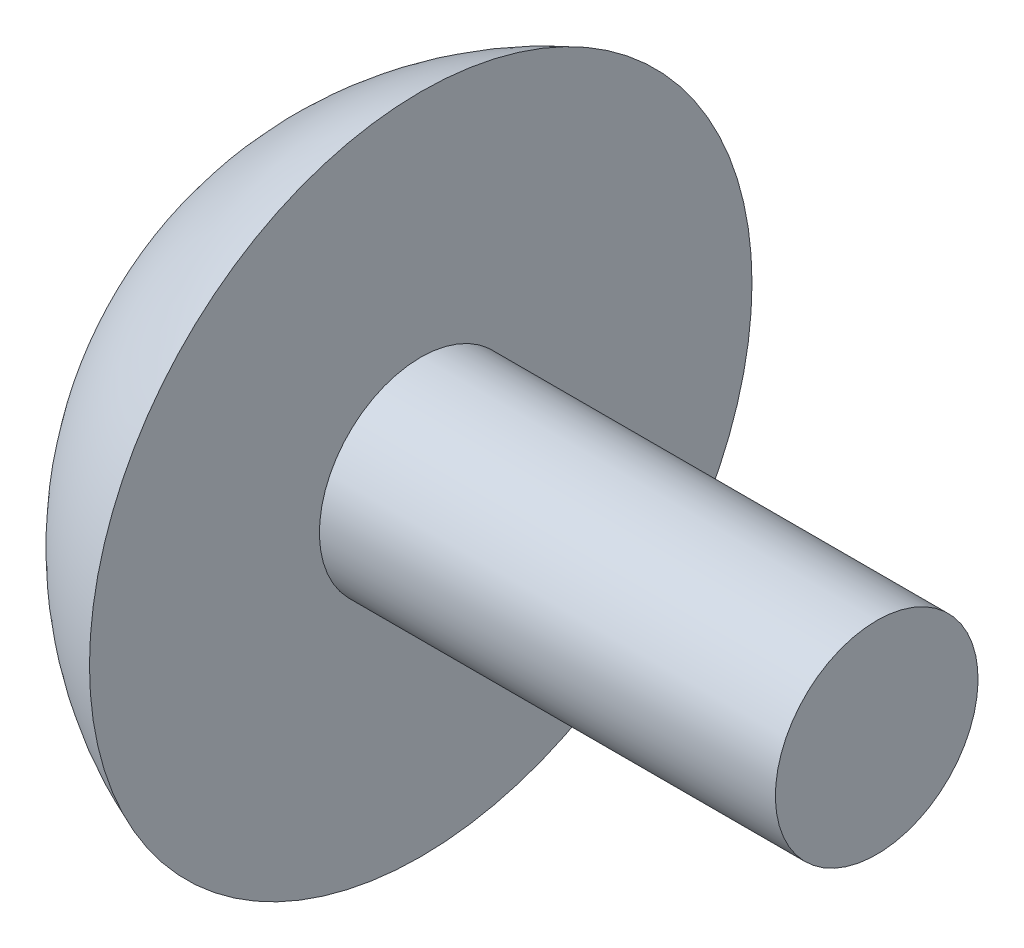
from build123d import *


with BuildPart() as part:
    # Esquisse5 → Révolution2 (revolve)
    with BuildSketch(Plane.XY):
        with BuildLine():
            Line((0, 0), (-13.5, 0))
            ThreePointArc((-13.5, 0), (-12.266281297, -3.968626967), (-9, -6.538348415))
            Line((-9, -6.538348415), (-9, -2))
            Line((-9, -2), (0, -2))
            Line((0, -2), (0, 0))
        make_face()
    revolve(axis=Axis((0, 0, 0), (-1, 0, 0)))


solid = part.part
